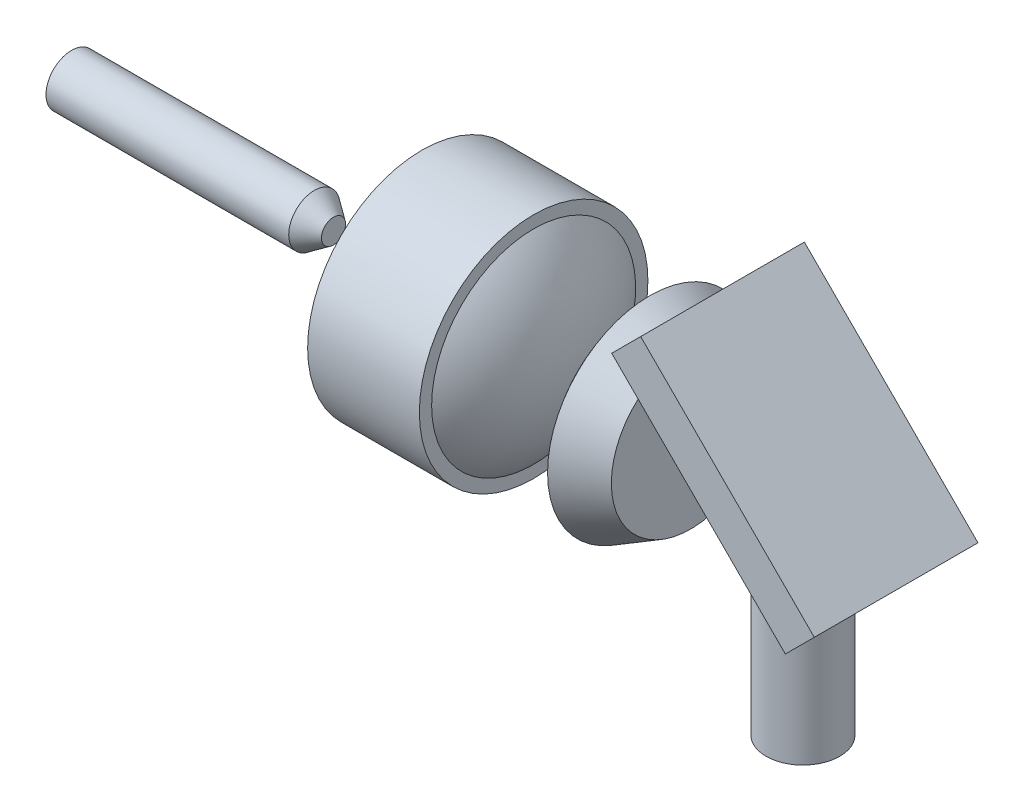
from build123d import *

# Parameters (mm, degrees)
BOSS_EXTRUDE1_DEPTH = 2
SKETCH1_7_W         = 0.9
SKETCH1_7_H         = 3.93


with BuildPart() as part:
    # Sketch1 → Boss-Extrude1 (new, symmetric)
    with BuildSketch(Plane.XY):
        Polygon((20.440710678, -1.429289322), (16.198069991, 2.813351365), (16.905176772, 3.520458146), (21.147817459, -0.722182541), align=None)
    extrude(amount=BOSS_EXTRUDE1_DEPTH, both=True)


with BuildPart() as body_2:
    # Sketch1_6 → Revolve4 (revolve)
    with BuildSketch(Plane.XY):
        with BuildLine():
            Line((16.13, 0), (16.13, 1.940845924))
            Line((16.13, 1.940845924), (15.13, 2.5))
            ThreePointArc((15.13, 2.5), (14.483714127, 1.323527484), (14.26, 0))
            Line((14.26, 0), (16.13, 0))
        make_face()
        with BuildLine():
            Line((12.29, 2.4925), (12.29, 2.7925))
            Line((12.29, 2.7925), (9.56, 2.7925))
            Line((9.56, 2.7925), (9.56, 0))
            Line((9.56, 0), (13.26, 0))
            ThreePointArc((13.26, 0), (13.00895401, 1.337297298), (12.29, 2.4925))
        make_face()
        Polygon((1, 0), (7.4, 0), (7.4, 0.29464991), (6.930638676, 0.625), (1, 0.625), align=None)
    revolve(axis=Axis((0, 0, 0), (1, 0, 0)))


with BuildPart() as body_3:
    # Sketch1_7 → Revolve5 (revolve)
    with BuildSketch(Plane.XY):
        with Locations((18.42, -2.965)):
            Rectangle(SKETCH1_7_W, SKETCH1_7_H)
    revolve(axis=Axis((18.87, -1, 0), (0, -1, 0)))


solid = Compound([part.part, body_2.part, body_3.part])
